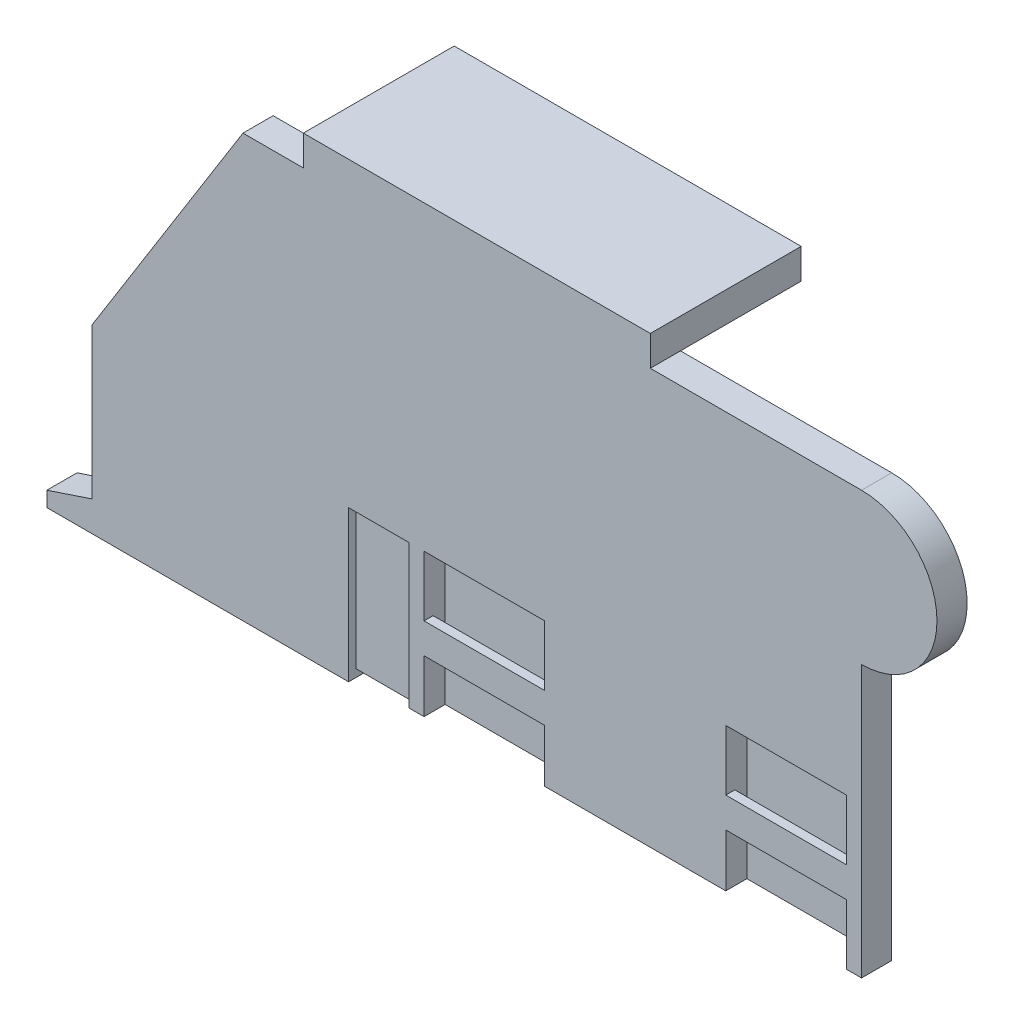
from build123d import *

# Parameters (mm, degrees)
MAINPLATE_DEPTH               = 2
TOPPLATE_W                    = 23
TOPPLATE_H                    = 10
BOSS_EXTRUDE6_DEPTH           = 2
SKETCH7_W                     = 8
SKETCH7_H                     = 0.8
SLOTSFORMETALTABS_DEPTH       = 10
SKETCH8_W                     = 8
SKETCH8_H                     = 4
ACCESSHOLESFORMETALTABS_DEPTH = 1
SKETCH9_W                     = 4
SKETCH9_H                     = 10
CUT_EXTRUDE3_DEPTH            = 0.5
SKETCH10_W                    = 33
SKETCH10_H                    = 0.5
CUT_EXTRUDE4_DEPTH            = 11


with BuildPart() as part:
    # Sketch1 → MainPlate (new body)
    with BuildSketch(Plane.XY):
        with BuildLine():
            Line((0, 0), (54, 0))
            Line((54, 0), (54, 18))
            ThreePointArc((54, 18), (59, 23), (54, 28))
            Line((54, 28), (13, 28))
            Line((13, 28), (3, 12))
            Line((3, 12), (3, 2))
            Line((3, 2), (0, 1))
            Line((0, 1), (0, 0))
        make_face()
    extrude(amount=-MAINPLATE_DEPTH)

    # TopPlate → Boss-Extrude6 (add)
    with BuildSketch(Plane(origin=(0, 28, 0), x_dir=(1, 0, 0), z_dir=(0, 1, 0))):
        with Locations((28.5, 5)):
            Rectangle(TOPPLATE_W, TOPPLATE_H)
    extrude(amount=BOSS_EXTRUDE6_DEPTH)

    # Sketch7 → SlotsForMetalTabs (cut)
    with BuildSketch(Plane.XZ):
        with Locations((49, -1)):
            Rectangle(SKETCH7_W, SKETCH7_H)
        with Locations((29, -1)):
            Rectangle(SKETCH7_W, SKETCH7_H)
    extrude(amount=-SLOTSFORMETALTABS_DEPTH, mode=Mode.SUBTRACT)

    # Sketch8 → AccessHolesForMetalTabs (cut)
    with BuildSketch(Plane.XY):
        with Locations((49, 8)):
            Rectangle(SKETCH8_W, SKETCH8_H)
        with Locations((49, 2)):
            Rectangle(SKETCH8_W, SKETCH8_H)
        with Locations((29, 2)):
            Rectangle(SKETCH8_W, SKETCH8_H)
        with Locations((29, 8)):
            Rectangle(SKETCH8_W, SKETCH8_H)
    extrude(amount=-ACCESSHOLESFORMETALTABS_DEPTH, mode=Mode.SUBTRACT)

    # Sketch9 → Cut-Extrude3 (cut)
    with BuildSketch(Plane.XY):
        with Locations((22, 5)):
            Rectangle(SKETCH9_W, SKETCH9_H)
    extrude(amount=-CUT_EXTRUDE3_DEPTH, mode=Mode.SUBTRACT)

    # Sketch10 → Cut-Extrude4 (cut, through all)
    with BuildSketch(Plane.XY):
        with Locations((36.5, 0.25)):
            Rectangle(SKETCH10_W, SKETCH10_H)
    extrude(amount=-CUT_EXTRUDE4_DEPTH, mode=Mode.SUBTRACT)


solid = part.part
